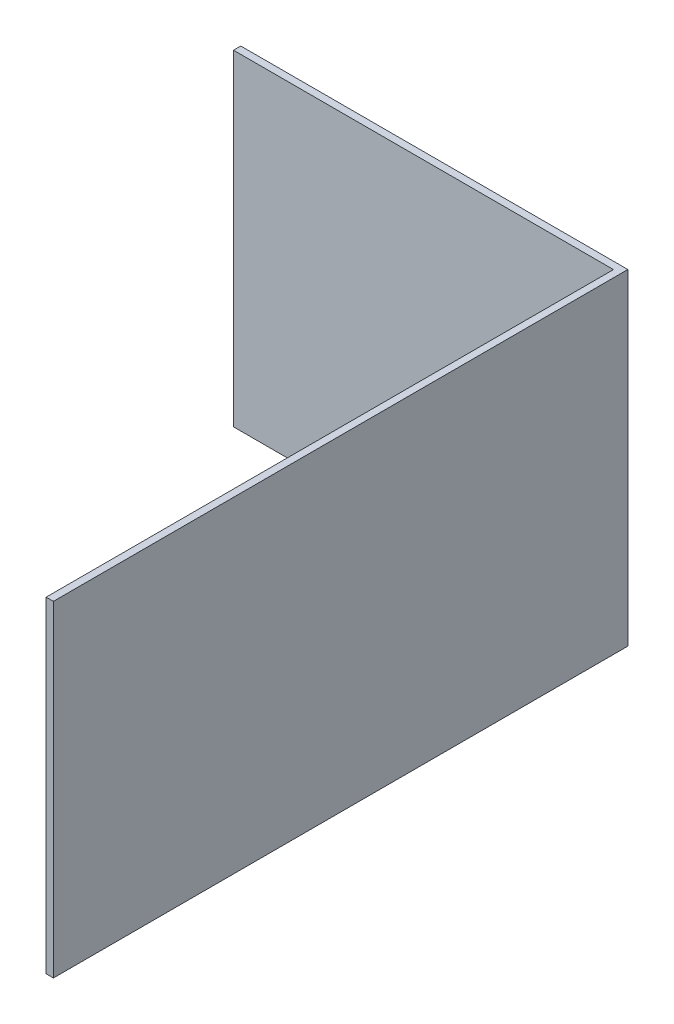
from build123d import *

# Parameters (mm, degrees)
BOSS_EXTRUDE1_DEPTH = 674.135566945


with BuildPart() as part:
    # Sketch1 → Boss-Extrude1 (new body)
    with BuildSketch(Plane(origin=(0, 0, 0), x_dir=(1, 0, 0), z_dir=(0, 1, 0))):
        Polygon((345.31088599, -749.286342906), (345.31088599, 423.210637315), (-440, 423.210637315), (-440, 438.210637314), (360, 438.210637314), (360.31088599, -749.286342906), align=None)
    extrude(amount=BOSS_EXTRUDE1_DEPTH)


solid = part.part
